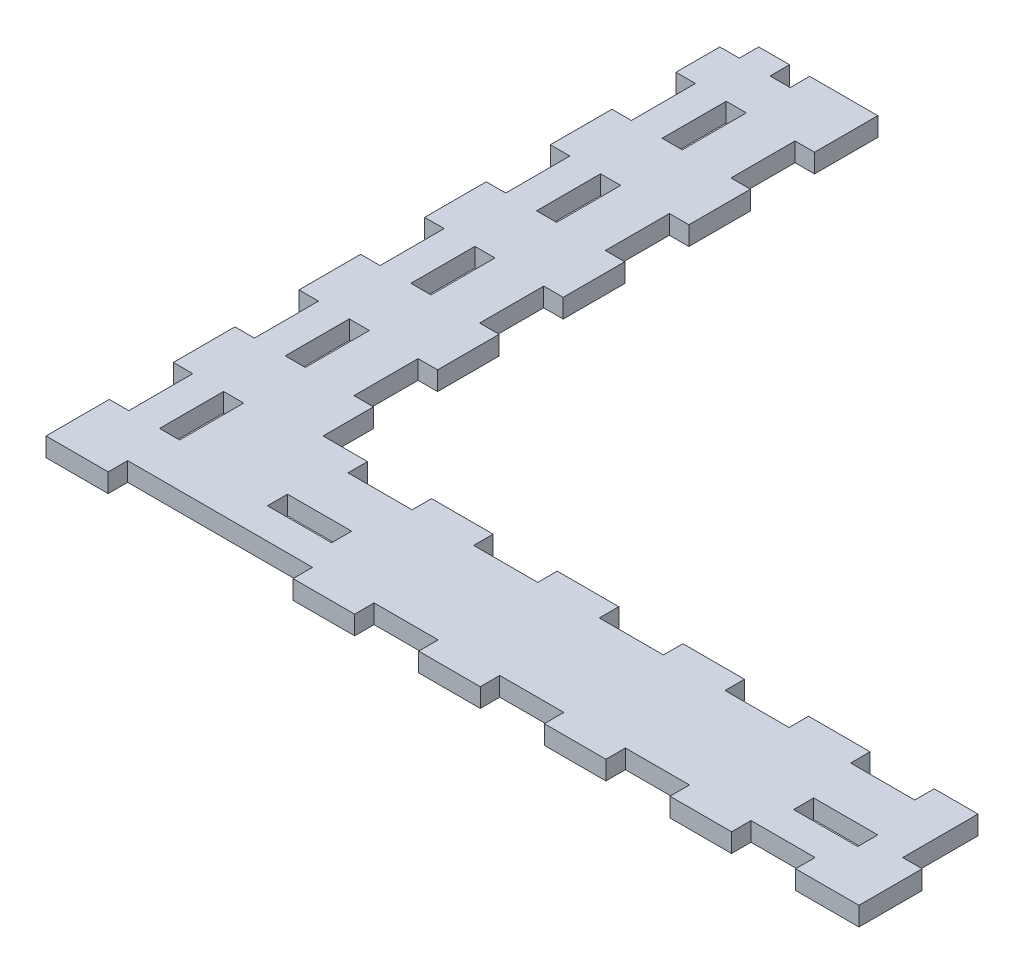
from build123d import *

# Parameters (mm, degrees)
BOSS_EXTRUDE1_DEPTH = 3
SKETCH4_W           = 10.2
SKETCH4_H           = 3.2
SKETCH4_W_2         = 3.2
SKETCH4_H_2         = 10.2
SKETCH4_W_3         = 29.422217102
SKETCH4_H_3         = 12.077782898
CUT_EXTRUDE1_DEPTH  = 4


with BuildPart() as part:
    # Sketch1 → Boss-Extrude1 (new body)
    with BuildSketch(Plane(origin=(0, 0, 0), x_dir=(1, 0, 0), z_dir=(0, 1, 0))):
        Polygon((129.394434203, 22.05), (22.05, 22.05), (22.05, 110.344434203), (0, 110.344434203), (0, 0), (129.394434203, 0), align=None)
    extrude(amount=-BOSS_EXTRUDE1_DEPTH)

    # Sketch4 → Cut-Extrude1 (cut, through all)
    with BuildSketch(Plane(origin=(0, 0, 0), x_dir=(1, 0, 0), z_dir=(0, 1, 0))):
        with Locations((54.222217102, 20.55)):
            Rectangle(SKETCH4_W, SKETCH4_H)
        with Locations((74.222217102, 20.55)):
            Rectangle(SKETCH4_W, SKETCH4_H)
        with Locations((114.222217102, 1.5)):
            Rectangle(SKETCH4_W, SKETCH4_H)
        with Locations((1.5, 15.172217102)):
            Rectangle(SKETCH4_W_2, SKETCH4_H_2)
        with Locations((34.222217102, 20.55)):
            Rectangle(SKETCH4_W, SKETCH4_H)
        with Locations((24.611108551, 1.5)):
            Rectangle(SKETCH4_W_3, SKETCH4_H)
        with Locations((32.35, 9.6)):
            Rectangle(SKETCH4_W, SKETCH4_H)
        with Locations((54.222217102, 1.5)):
            Rectangle(SKETCH4_W, SKETCH4_H)
        with Locations((74.222217102, 1.5)):
            Rectangle(SKETCH4_W, SKETCH4_H)
        with Locations((9.6, 15.172217102)):
            Rectangle(SKETCH4_W_2, SKETCH4_H_2)
        with Locations((1.5, 35.172217102)):
            Rectangle(SKETCH4_W_2, SKETCH4_H_2)
        with Locations((9.6, 35.172217102)):
            Rectangle(SKETCH4_W_2, SKETCH4_H_2)
        with Locations((20.55, 35.172217102)):
            Rectangle(SKETCH4_W_2, SKETCH4_H_2)
        with Locations((1.5, 108.844434203)):
            Rectangle(SKETCH4_W_2, SKETCH4_H)
        with Locations((9.6, 108.844434203)):
            Rectangle(SKETCH4_W_2, SKETCH4_H)
        with Locations((9.6, 95.172217102)):
            Rectangle(SKETCH4_W_2, SKETCH4_H_2)
        with Locations((1.5, 95.172217102)):
            Rectangle(SKETCH4_W_2, SKETCH4_H_2)
        with Locations((1.5, 75.172217102)):
            Rectangle(SKETCH4_W_2, SKETCH4_H_2)
        with Locations((9.6, 75.172217102)):
            Rectangle(SKETCH4_W_2, SKETCH4_H_2)
        with Locations((20.55, 95.172217102)):
            Rectangle(SKETCH4_W_2, SKETCH4_H_2)
        with Locations((20.55, 75.172217102)):
            Rectangle(SKETCH4_W_2, SKETCH4_H_2)
        with Locations((1.5, 55.172217102)):
            Rectangle(SKETCH4_W_2, SKETCH4_H_2)
        with Locations((9.6, 55.172217102)):
            Rectangle(SKETCH4_W_2, SKETCH4_H_2)
        with Locations((20.55, 55.172217102)):
            Rectangle(SKETCH4_W_2, SKETCH4_H_2)
        with Locations((127.894434203, 16.111108551)):
            Rectangle(SKETCH4_W_2, SKETCH4_H_3)
        with Locations((94.222217102, 1.5)):
            Rectangle(SKETCH4_W, SKETCH4_H)
        with Locations((114.222217102, 20.55)):
            Rectangle(SKETCH4_W, SKETCH4_H)
        with Locations((94.222217102, 20.55)):
            Rectangle(SKETCH4_W, SKETCH4_H)
        with Locations((116.094434203, 9.6)):
            Rectangle(SKETCH4_W, SKETCH4_H)
    extrude(amount=-CUT_EXTRUDE1_DEPTH, mode=Mode.SUBTRACT)


solid = part.part
